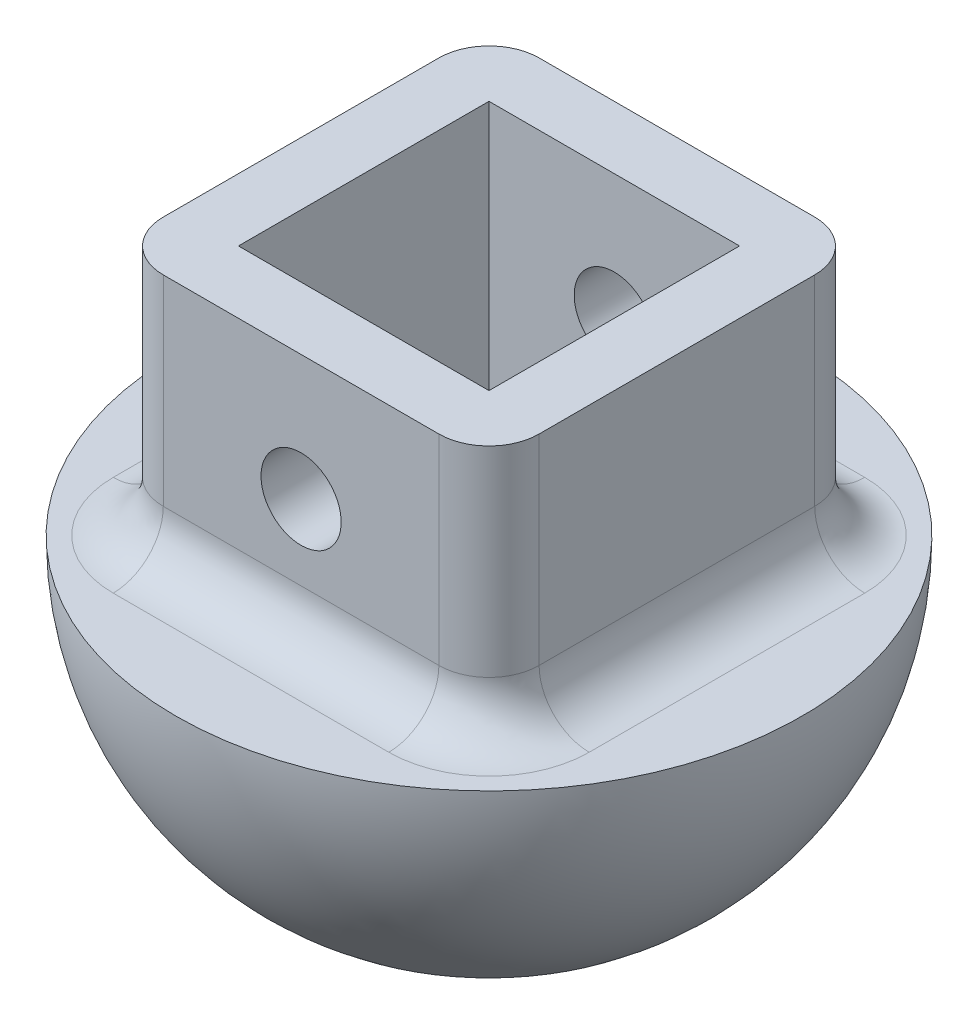
from build123d import *

# Parameters (mm, degrees)
REVOLVE2_ANGLE          = 180
SKETCH1_W               = 15
SKETCH1_H               = 15
SKETCH1_W_2             = 10
SKETCH1_H_2             = 10
BOSS_EXTRUDE1_DEPTH     = 10
SKETCH2_R               = 1.6
CUT_EXTRUDE1_DEPTH      = 20
CUT_EXTRUDE1_DEPTH_BACK = 10
FILLET1_R               = 2


with BuildPart() as part:
    # Sketch4 → Revolve2 (revolve)
    with BuildSketch(Plane(origin=(0, 0, 0), x_dir=(1, 0, 0), z_dir=(0, 1, 0))):
        with BuildLine():
            Line((12.5, 0), (-12.5, 0))
            ThreePointArc((-12.5, 0), (0, -12.5), (12.5, 0))
        make_face()
    revolve(axis=Axis((-12.5, 0, 0), (1, 0, 0)), revolution_arc=REVOLVE2_ANGLE)

    # Sketch1 → Boss-Extrude1 (add)
    with BuildSketch(Plane(origin=(0, 0, 0), x_dir=(1, 0, 0), z_dir=(0, 1, 0))):
        Rectangle(SKETCH1_W, SKETCH1_H)
        Rectangle(SKETCH1_W_2, SKETCH1_H_2, mode=Mode.SUBTRACT)
    extrude(amount=BOSS_EXTRUDE1_DEPTH)

    # Sketch2 → Cut-Extrude1 (cut, two sides)
    with BuildSketch(Plane(origin=(0, 0, 5), x_dir=(-1, 0, 0), z_dir=(0, 0, -1))) as cut_extrude1_sk:
        with Locations((0, 5)):
            Circle(SKETCH2_R)
    extrude(amount=CUT_EXTRUDE1_DEPTH, mode=Mode.SUBTRACT)
    extrude(cut_extrude1_sk.sketch, amount=-CUT_EXTRUDE1_DEPTH_BACK, mode=Mode.SUBTRACT)

    # Fillet1
    fillet1_edges = [part.edges().sort_by_distance(p)[0] for p in [
        (7.5, 0, 0),
        (7.5, 5, 7.5),
        (0, 0, -7.5),
        (7.5, 5, -7.5),
        (-7.5, 0, 0),
        (-7.5, 5, -7.5),
        (0, 0, 7.5),
        (-7.5, 5, 7.5),
    ]]
    fillet(fillet1_edges, radius=FILLET1_R)


solid = part.part
